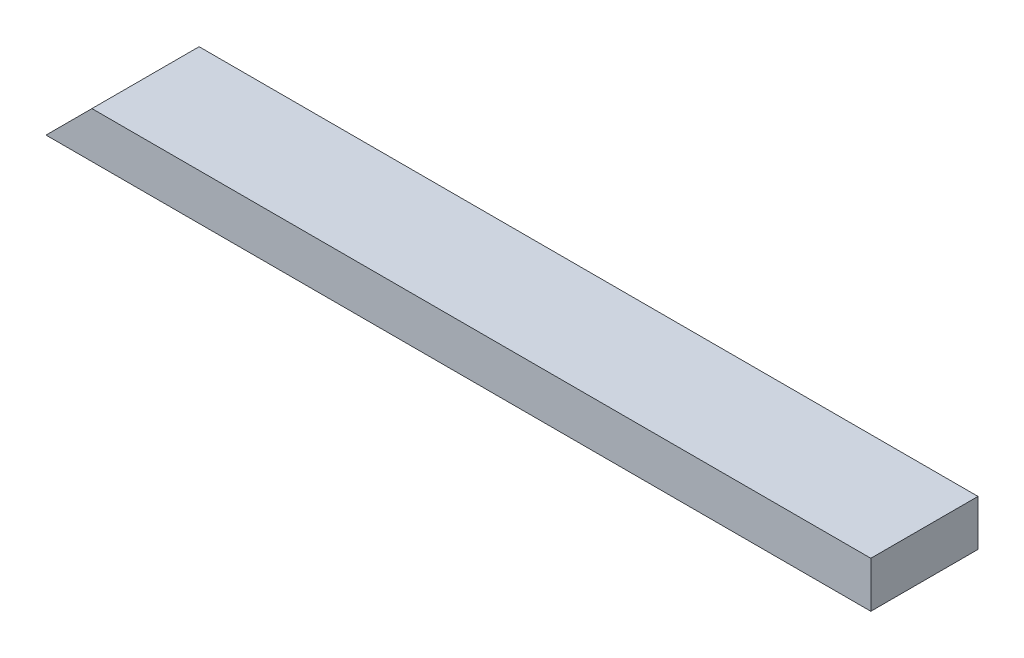
from build123d import *

# Parameters (mm, degrees)
SKETCH1_W           = 684.2125
SKETCH1_H           = 88.9
BOSS_EXTRUDE1_DEPTH = 38.1
CUT_EXTRUDE1_DEPTH  = 89.9


with BuildPart() as part:
    # Sketch1 → Boss-Extrude1 (new body)
    with BuildSketch(Plane(origin=(0, 0, 0), x_dir=(1, 0, 0), z_dir=(0, 1, 0))):
        with Locations((342.10625, 44.45)):
            Rectangle(SKETCH1_W, SKETCH1_H)
    extrude(amount=BOSS_EXTRUDE1_DEPTH)

    # Sketch2 → Cut-Extrude1 (cut, through all)
    with BuildSketch(Plane.XY):
        Polygon((0, 0), (38.1, 38.1), (0, 38.1), align=None)
    extrude(amount=-CUT_EXTRUDE1_DEPTH, mode=Mode.SUBTRACT)


solid = part.part
